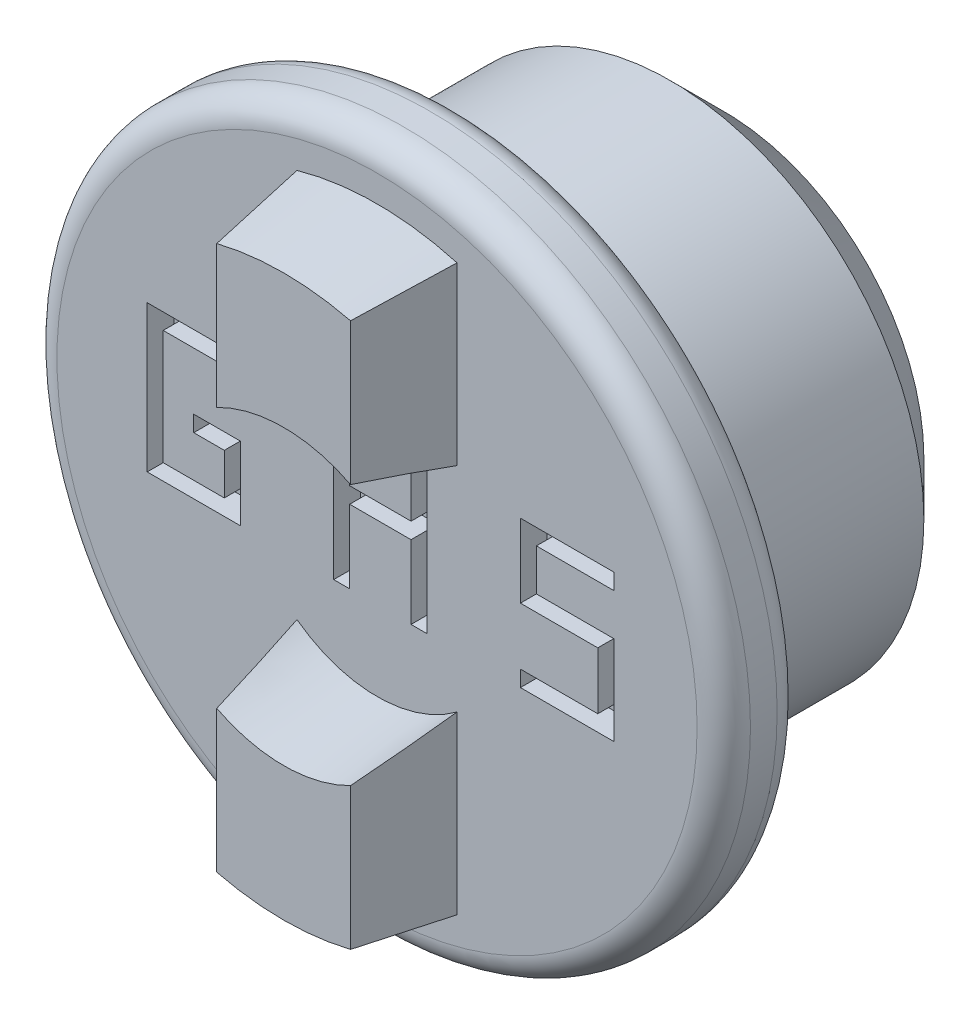
from build123d import *

# Parameters (mm, degrees)
SKETCH1_R           = 9.5
BOSS_EXTRUDE1_DEPTH = 10
CHAMFER1_SIZE       = 2
SKETCH2_R           = 13
BOSS_EXTRUDE2_DEPTH = 3
BOSS_EXTRUDE3_DEPTH = 3.5
BOSS_EXTRUDE3_TAPER = 8
FILLET1_R           = 1
SKETCH3_W           = 2.3
SKETCH3_H           = 1.548065916
CUT_EXTRUDE1_DEPTH  = 1


with BuildPart() as part:
    # Sketch1 → Boss-Extrude1 (new body)
    with BuildSketch(Plane.XY):
        Circle(SKETCH1_R)
    extrude(amount=BOSS_EXTRUDE1_DEPTH)

    # Chamfer1
    chamfer1_edges = [part.edges().sort_by_distance(p)[0] for p in [
        (-9.5, 0, 0),
    ]]
    chamfer(chamfer1_edges, length=CHAMFER1_SIZE)

    # Sketch2 → Boss-Extrude2 (add)
    with BuildSketch(Plane.XY.offset(10)):
        Circle(SKETCH2_R)
    extrude(amount=BOSS_EXTRUDE2_DEPTH)

    # Sketch4 → Boss-Extrude3 (add)
    with BuildSketch(Plane.XY.offset(13)):
        with BuildLine():
            ThreePointArc((3, 10.583005244), (0, 11), (-3, 10.583005244))
            Line((-3, 10.583005244), (-3, 4))
            ThreePointArc((-3, 4), (0, 5), (3, 4))
            Line((3, 4), (3, 10.583005244))
        make_face()
        with BuildLine():
            ThreePointArc((3, -4), (0, -5), (-3, -4))
            Line((-3, -4), (-3, -10.583005244))
            ThreePointArc((-3, -10.583005244), (0, -11), (3, -10.583005244))
            Line((3, -10.583005244), (3, -4))
        make_face()
    extrude(amount=BOSS_EXTRUDE3_DEPTH, taper=BOSS_EXTRUDE3_TAPER)

    # Fillet1
    fillet1_edges = [part.edges().sort_by_distance(p)[0] for p in [
        (-13, 0, 10),
        (-13, 0, 13),
    ]]
    fillet(fillet1_edges, radius=FILLET1_R)

    # Sketch3 → Cut-Extrude1 (cut)
    with BuildSketch(Plane.XY.offset(13)):
        Polygon((-1.625120105, -2.013905208), (-1.625120105, 3.480258709), (1.874879895, 3.480258709), (1.874879895, -2.019741291), (1.274879895, -2.019741291), (1.274879895, 0.732192793), (-1.025120105, 0.732192793), (-1.025120105, -2.013905208), align=None)
        with Locations((0.124879895, 2.106225751)):
            Rectangle(SKETCH3_W, SKETCH3_H, mode=Mode.SUBTRACT)
        Polygon((5.374879895, 3.480258709), (8.874879895, 3.480258709), (8.874879895, 2.880258709), (5.974879895, 2.880258709), (5.974879895, 1.320855687), (8.874879895, 1.320855687), (8.874879895, -1.419741291), (8.874879895, -2.019741291), (5.374879895, -2.019741291), (5.374879895, -1.419741291), (8.274879895, -1.419741291), (8.274879895, 0.720855687), (5.374879895, 0.720855687), align=None)
        Polygon((-8.615536657, 3.480258709), (-8.615536657, -2.013905208), (-5.125120105, -2.013905208), (-5.125120105, 0.73317675), (-6.870328381, 0.73317675), (-6.870328381, 0.13317675), (-5.725120105, 0.13317675), (-5.725120105, -1.413905208), (-8.015536657, -1.413905208), (-8.015536657, 2.880258709), (-5.125120105, 2.880258709), (-5.125120105, 3.480258709), align=None)
    extrude(amount=-CUT_EXTRUDE1_DEPTH, mode=Mode.SUBTRACT)


solid = part.part
